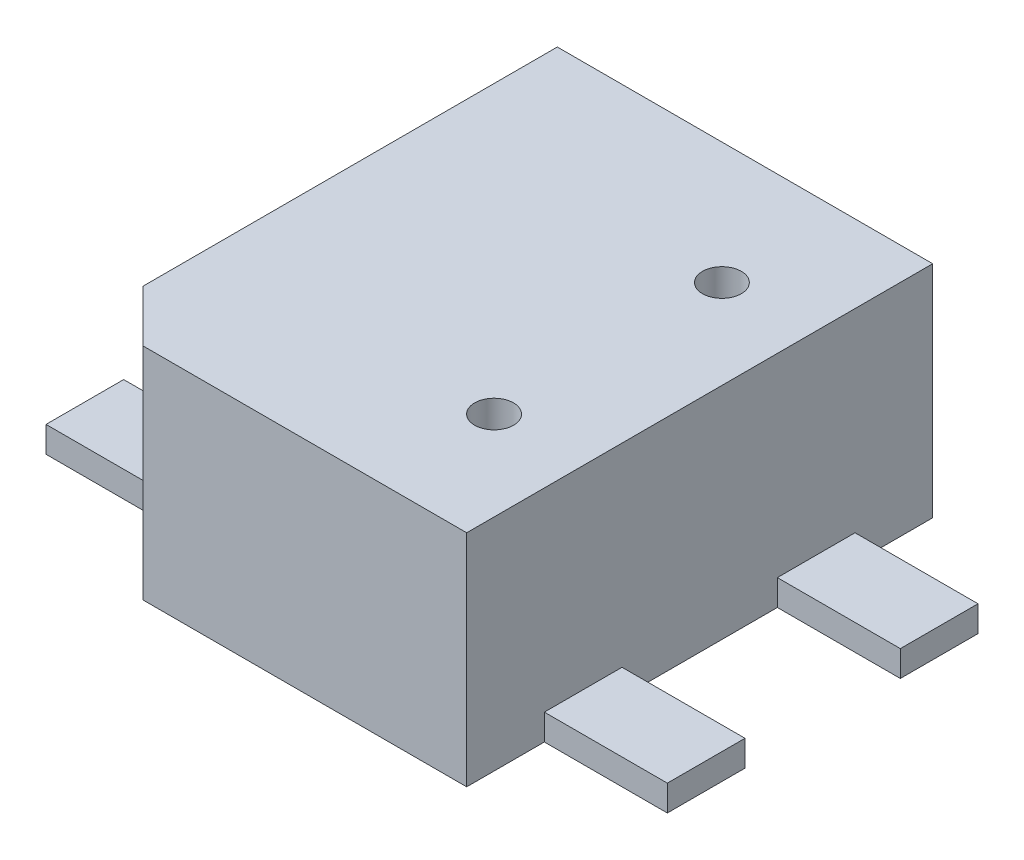
from build123d import *

# Parameters (mm, degrees)
SKETCH_1_W          = 2.9
SKETCH_1_H          = 3.6
EXTRUDE_1_DEPTH     = 1.7
CUT_EXTRUDE_1_DEPTH = 1.7
SKETCH_5_W          = 4.8
SKETCH_5_H          = 0.6
EXTRUDE_2_DEPTH     = 0.2
SKETCH_4_R          = 0.15
CUT_EXTRUDE_2_DEPTH = 1.7


with BuildPart() as part:
    # 스케치1 → 보스-돌출1 (new body)
    with BuildSketch(Plane(origin=(0, 0, 0), x_dir=(1, 0, 0), z_dir=(0, 1, 0))):
        Rectangle(SKETCH_1_W, SKETCH_1_H)
    extrude(amount=EXTRUDE_1_DEPTH)

    # 스케치3 → 컷-돌출1 (cut)
    with BuildSketch(Plane(origin=(0, 1.7, 0), x_dir=(1, 0, 0), z_dir=(0, 1, 0))):
        Polygon((-1.45047429, -1.4), (-1.05, -1.80047429), (-1.45, -1.8), align=None)
    extrude(amount=-CUT_EXTRUDE_1_DEPTH, mode=Mode.SUBTRACT)

    # 스케치5 → 보스-돌출2 (add)
    with BuildSketch(Plane.XZ):
        with Locations((0, -0.9)):
            Rectangle(SKETCH_5_W, SKETCH_5_H)
        with Locations((0, 0.9)):
            Rectangle(SKETCH_5_W, SKETCH_5_H)
    extrude(amount=-EXTRUDE_2_DEPTH)

    # 스케치4 → 컷-돌출2 (cut)
    with BuildSketch(Plane(origin=(0, 1.7, 0), x_dir=(1, 0, 0), z_dir=(0, 1, 0))):
        with Locations((0.76162028, 0.86)):
            Circle(SKETCH_4_R)
        with Locations((0.76162028, -0.9)):
            Circle(SKETCH_4_R)
    extrude(amount=-CUT_EXTRUDE_2_DEPTH, mode=Mode.SUBTRACT)


solid = part.part
